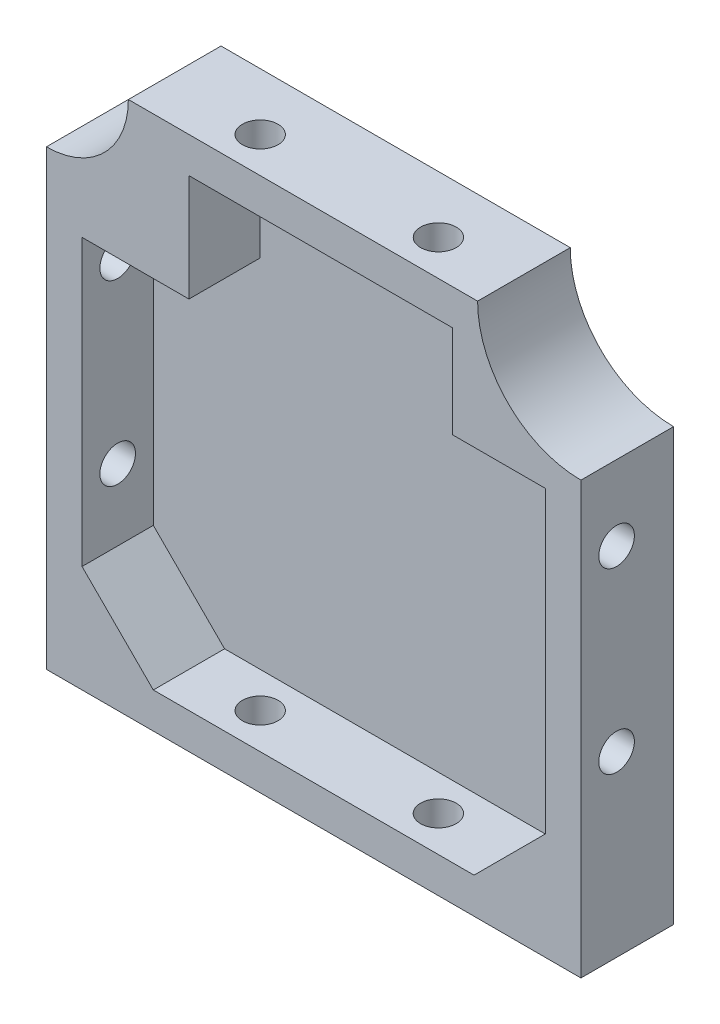
from build123d import *

# Parameters (mm, degrees)
BOSS_EXTRU_1_DEPTH        = 13
COQUE1_T                  = -5
COQUE1_THICKNESS_2_FACE_W = 65
COQUE1_THICKNESS_2_FACE_H = 65
COQUE1_THICKNESS_2_DEPTH  = 2
ENL_V_MAT_EXTRU_1_REACH   = 88.587
ESQUISSE2_R               = 2.5
ENL_V_MAT_EXTRU_2_REACH   = 95.396
ESQUISSE3_R               = 2.5
ESQUISSE4_W               = 18
ESQUISSE4_H               = 18
ESQUISSE4_W_2             = 15
ESQUISSE4_H_2             = 15
BOSS_EXTRU_2_DEPTH        = 10
ESQUISSE5_R               = 11.5
ESQUISSE5_R_2             = 14.5
ENL_V_MAT_EXTRU_3_DEPTH   = 13


with BuildPart() as part:
    # Esquisse1 → Boss.-Extru.1 (new body)
    with BuildSketch(Plane.XY):
        Polygon((44.118436308, 33.728448276), (54.118436308, 33.728448276), (54.118436308, 23.728448276), (54.118436308, -41.271551724), (-20.881563692, -41.271551724), (-20.881563692, 33.728448276), align=None)
    extrude(amount=BOSS_EXTRU_1_DEPTH)

    # Coque1
    coque1_openings = [part.faces().sort_by_distance(p)[0] for p in [
        (16.618436308, -3.771551724, 13),
    ]]
    offset(amount=COQUE1_T, openings=coque1_openings, kind=Kind.INTERSECTION)

    # Coque1 thickness 2 face (on inner face of the shell) → Coque1 thickness 2 (cut)
    with BuildSketch(Plane(origin=(16.618436308, -3.771551724, 5), x_dir=(-1, 0, 0), z_dir=(0, 0, -1))):
        Rectangle(COQUE1_THICKNESS_2_FACE_W, COQUE1_THICKNESS_2_FACE_H)
    extrude(amount=COQUE1_THICKNESS_2_DEPTH, mode=Mode.SUBTRACT)

    # Enlèv. mat.-Extru.1: up to this face of the body (flat: up to its plane)
    enl_v_mat_extru_1_end = Plane(part.part.faces().sort_by_distance((54.118436308, -3.771551724, 6.5))[0])
    # Esquisse2 → Enlèv. mat.-Extru.1 (cut, up to the picked face)
    with BuildSketch(Plane.ZY.offset(20.881563692), mode=Mode.PRIVATE) as enl_v_mat_extru_1_sk1:
        with Locations(Location((8, -16.271551724, 0), (0, 0, 270))):
            Circle(ESQUISSE2_R)
    enl_v_mat_extru_1_tool1 = split(extrude(enl_v_mat_extru_1_sk1.sketch, amount=-ENL_V_MAT_EXTRU_1_REACH, mode=Mode.PRIVATE), bisect_by=enl_v_mat_extru_1_end, keep=Keep.BOTH, mode=Mode.PRIVATE)
    # Esquisse2 → Enlèv. mat.-Extru.1 (cut, up to the picked face)
    with BuildSketch(Plane.ZY.offset(20.881563692), mode=Mode.PRIVATE) as enl_v_mat_extru_1_sk2:
        with Locations(Location((8, 8.728448276, 0), (0, 0, 270))):
            Circle(ESQUISSE2_R)
    enl_v_mat_extru_1_tool2 = split(extrude(enl_v_mat_extru_1_sk2.sketch, amount=-ENL_V_MAT_EXTRU_1_REACH, mode=Mode.PRIVATE), bisect_by=enl_v_mat_extru_1_end, keep=Keep.BOTH, mode=Mode.PRIVATE)
    add(enl_v_mat_extru_1_tool1.solids().sort_by(Axis((-20.881564, -16.271552, 8), (1, 0, 0)))[0], mode=Mode.SUBTRACT)
    add(enl_v_mat_extru_1_tool2.solids().sort_by(Axis((-20.881564, 8.728448, 8), (1, 0, 0)))[0], mode=Mode.SUBTRACT)

    # Enlèv. mat.-Extru.2: up to this face of the body (flat: up to its plane)
    enl_v_mat_extru_2_end = Plane(part.part.faces().sort_by_distance((16.618436308, 33.728448276, 6.5))[0])
    # Esquisse3 → Enlèv. mat.-Extru.2 (cut, up to the picked face)
    with BuildSketch(Plane.XZ.offset(41.271551724), mode=Mode.PRIVATE) as enl_v_mat_extru_2_sk1:
        with Locations(Location((4.118436308, 8, 0), (0, 0, 270))):
            Circle(ESQUISSE3_R)
    enl_v_mat_extru_2_tool1 = split(extrude(enl_v_mat_extru_2_sk1.sketch, amount=-ENL_V_MAT_EXTRU_2_REACH, mode=Mode.PRIVATE), bisect_by=enl_v_mat_extru_2_end, keep=Keep.BOTH, mode=Mode.PRIVATE)
    # Esquisse3 → Enlèv. mat.-Extru.2 (cut, up to the picked face)
    with BuildSketch(Plane.XZ.offset(41.271551724), mode=Mode.PRIVATE) as enl_v_mat_extru_2_sk2:
        with Locations(Location((29.118436308, 8, 0), (0, 0, 270))):
            Circle(ESQUISSE3_R)
    enl_v_mat_extru_2_tool2 = split(extrude(enl_v_mat_extru_2_sk2.sketch, amount=-ENL_V_MAT_EXTRU_2_REACH, mode=Mode.PRIVATE), bisect_by=enl_v_mat_extru_2_end, keep=Keep.BOTH, mode=Mode.PRIVATE)
    add(enl_v_mat_extru_2_tool1.solids().sort_by(Axis((4.118436, -41.271552, 8), (0, 1, 0)))[0], mode=Mode.SUBTRACT)
    add(enl_v_mat_extru_2_tool2.solids().sort_by(Axis((29.118436, -41.271552, 8), (0, 1, 0)))[0], mode=Mode.SUBTRACT)

    # Esquisse4 → Boss.-Extru.2 (add)
    with BuildSketch(Plane.XY.offset(3)):
        Polygon((-15.881563692, -26.271551724), (-5.881563692, -36.271551724), (-15.881563692, -36.271551724), align=None)
        with Locations((45.118436308, 24.728448276)):
            Rectangle(ESQUISSE4_W, ESQUISSE4_H)
        Polygon((49.118436308, -36.271551724), (49.118436308, -26.271551724), (39.118436308, -36.271551724), align=None)
        with Locations((-8.381563692, 21.228448276)):
            Rectangle(ESQUISSE4_W_2, ESQUISSE4_H_2)
    extrude(amount=BOSS_EXTRU_2_DEPTH)

    # Esquisse5 → Enlèv. mat.-Extru.3 (cut)
    with BuildSketch(Plane.XY.offset(13)):
        with Locations((-20.881563692, 33.728448276)):
            Circle(ESQUISSE5_R)
        with Locations((54.118436308, 33.728448276)):
            Circle(ESQUISSE5_R_2)
    extrude(amount=-ENL_V_MAT_EXTRU_3_DEPTH, mode=Mode.SUBTRACT)


solid = part.part
